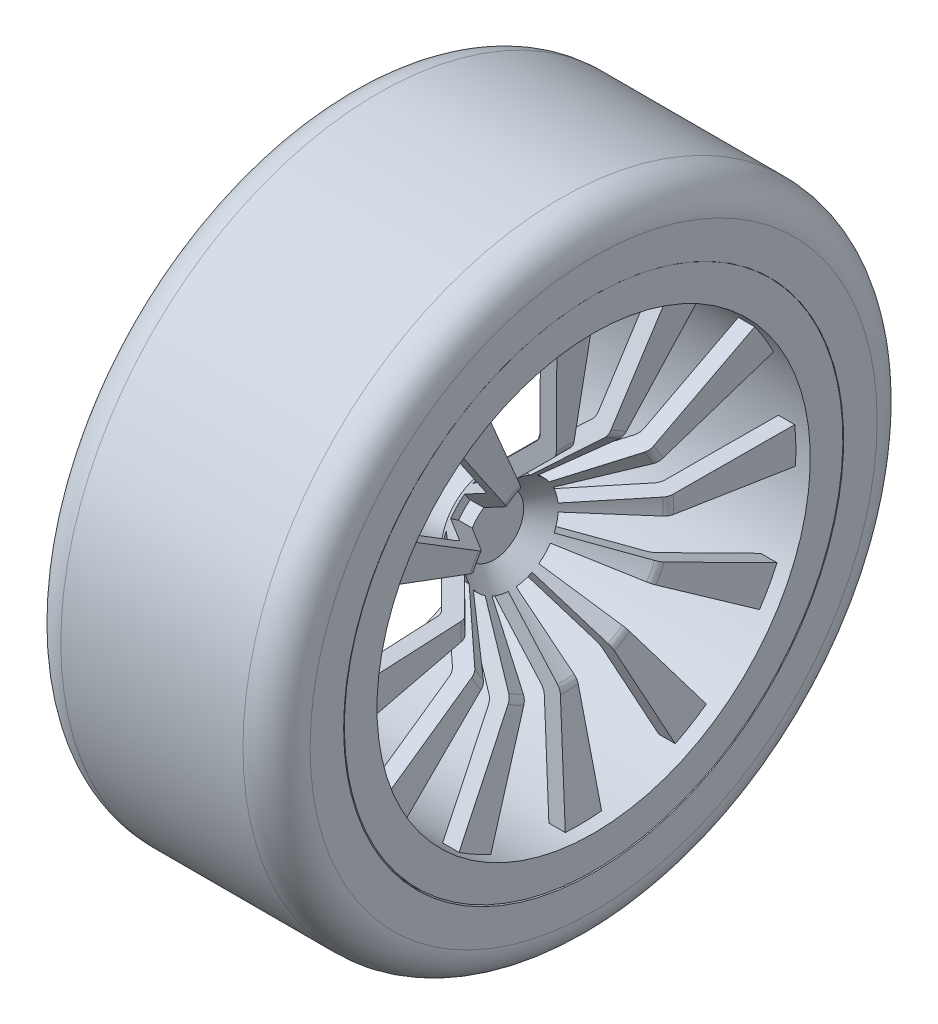
from build123d import *

# Parameters (mm, degrees)
CUT_EXTRUDE4_DEPTH = 10
CIRPATTERN1_COUNT  = 12


with BuildPart() as part:
    # Sketch2 → Revolve5 (revolve)
    with BuildSketch(Plane.XY):
        with BuildLine():
            Line((2.602094, -19.5), (2.602094, -22.6))
            Line((2.602094, -22.6), (0, -22.6))
            Line((0, -22.6), (0, -19.5))
            Line((0, -19.5), (-5, -19.5))
            Line((-5, -19.5), (-5, -18.2))
            ThreePointArc((-5, -18.2), (-4.853553, -17.846447), (-4.5, -17.7))
            Line((-4.5, -17.7), (2, -17.7))
            Line((2, -17.7), (8.238019, -11.483529))
            ThreePointArc((8.238019, -11.483529), (8.502511, -11.111048), (8.627938, -10.671768))
            Line((8.627938, -10.671768), (9.789952, 0))
            Line((9.789952, 0), (-13, 0))
            Line((-13, 0), (-13, 3.4))
            Line((-13, 3.4), (-11.5, 3.4))
            Line((-11.5, 3.4), (-11.5, 2.5))
            ThreePointArc((-11.5, 2.5), (-11.265685, 1.934315), (-10.7, 1.7))
            Line((-10.7, 1.7), (10.7, 1.7))
            ThreePointArc((10.7, 1.7), (11.265685, 1.934315), (11.5, 2.5))
            Line((11.5, 2.5), (11.5, 3.4))
            Line((11.5, 3.4), (13, 3.4))
            Line((13, 3.4), (13, 0))
            Line((13, 0), (11.5, 0))
            Line((11.5, 0), (10.247979, -11.498374))
            ThreePointArc((10.247979, -11.498374), (10.134716, -11.895056), (9.895871, -12.231417))
            Line((9.895871, -12.231417), (2.602094, -19.5))
        make_face()
    revolve(axis=Axis((13, -22.6, 0), (-1, 0, 0)))

    # Sketch4 → Cut-Extrude4 (cut)
    with BuildSketch(Plane(origin=(13, 0, 0), x_dir=(0, 0, -1), z_dir=(1, 0, 0))):
        with BuildLine():
            ThreePointArc((-0.504868, -17.726079), (-1.359538, -17.892383), (-2.171281, -18.207331))
            Line((-2.171281, -18.207331), (-10.01448, -2.339936))
            ThreePointArc((-10.01448, -2.339936), (-6.270524, -0.887319), (-2.328575, -0.120282))
            Line((-2.328575, -0.120282), (-0.504868, -17.726079))
        make_face()
    cut_extrude4 = extrude(amount=-CUT_EXTRUDE4_DEPTH, mode=Mode.SUBTRACT)

    # CirPattern1: Cut-Extrude4 ×12 about axis
    cirpattern1_axis = Axis((0, -22.6, 0), (1, 0, 0))
    for i in range(1, CIRPATTERN1_COUNT):
        add(cut_extrude4.rotate(cirpattern1_axis, i * 360 / CIRPATTERN1_COUNT), mode=Mode.SUBTRACT)


with BuildPart() as body_2:
    # Sketch6 → Revolve7 (revolve)
    with BuildSketch(Plane.XY):
        with BuildLine():
            Line((-13, 3.4), (-11.5, 3.4))
            Line((-11.5, 3.4), (-11.5, 2.5))
            Line((-11.5, 2.5), (-10.7, 1.7))
            Line((-10.7, 1.7), (10.7, 1.7))
            Line((10.7, 1.7), (11.5, 2.5))
            Line((11.5, 2.5), (11.5, 3.4))
            Line((11.5, 3.4), (13, 3.4))
            Line((13, 3.4), (13, 6.9))
            ThreePointArc((13, 6.9), (11.974874, 9.374874), (9.5, 10.4))
            Line((9.5, 10.4), (-9.5, 10.4))
            ThreePointArc((-9.5, 10.4), (-11.974874, 9.374874), (-13, 6.9))
            Line((-13, 6.9), (-13, 3.4))
        make_face()
    revolve(axis=Axis((-14.354867, -22.677594, 0), (1, 0, 0)))


solid = Compound([part.part, body_2.part])
